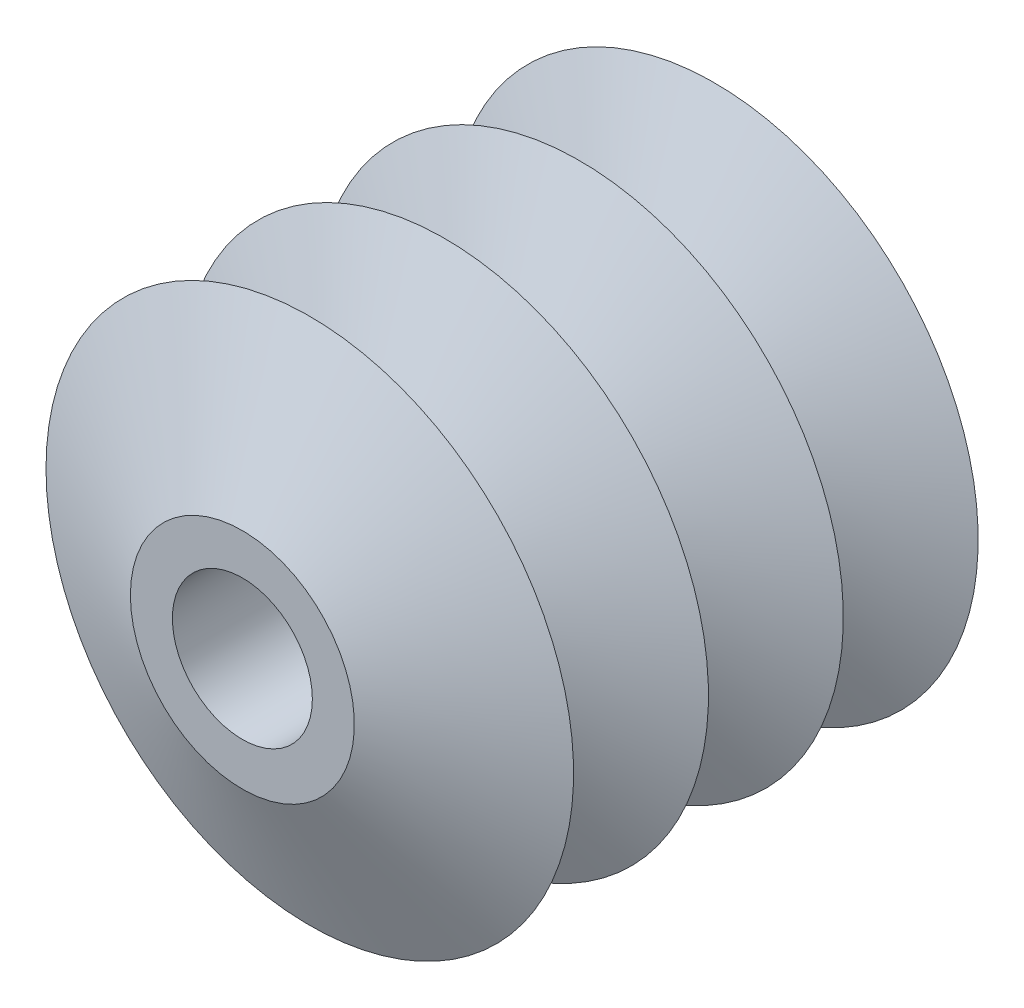
from build123d import *

# Parameters (mm, degrees)
TALADRO_DE_MARGEN_PARA_M162_D = 17.5


with BuildPart() as part:
    # Croquis1 → Revolución3 (revolve)
    with BuildSketch(Plane(origin=(0, 0, 0), x_dir=(1, 0, 0), z_dir=(0, 1, 0))):
        Polygon((0, 33.721279245), (0, -33.721279245), (14, -33.721279245), (32.980229853, -25.290959433), (14, -16.860639622), (32.980229853, -8.430319811), (14, 0), (32.980229853, 8.430319811), (14, 16.860639622), (32.980229853, 25.290959433), (14, 33.721279245), align=None)
    revolve(axis=Axis((0, 0, -33.721279245), (0, 0, 1)))

    # Taladro de margen para M162 (through all)
    with Locations(Plane.XY.offset(33.721279245)):
        with Locations((0, 0.129582741)):
            Hole(TALADRO_DE_MARGEN_PARA_M162_D / 2)


solid = part.part
